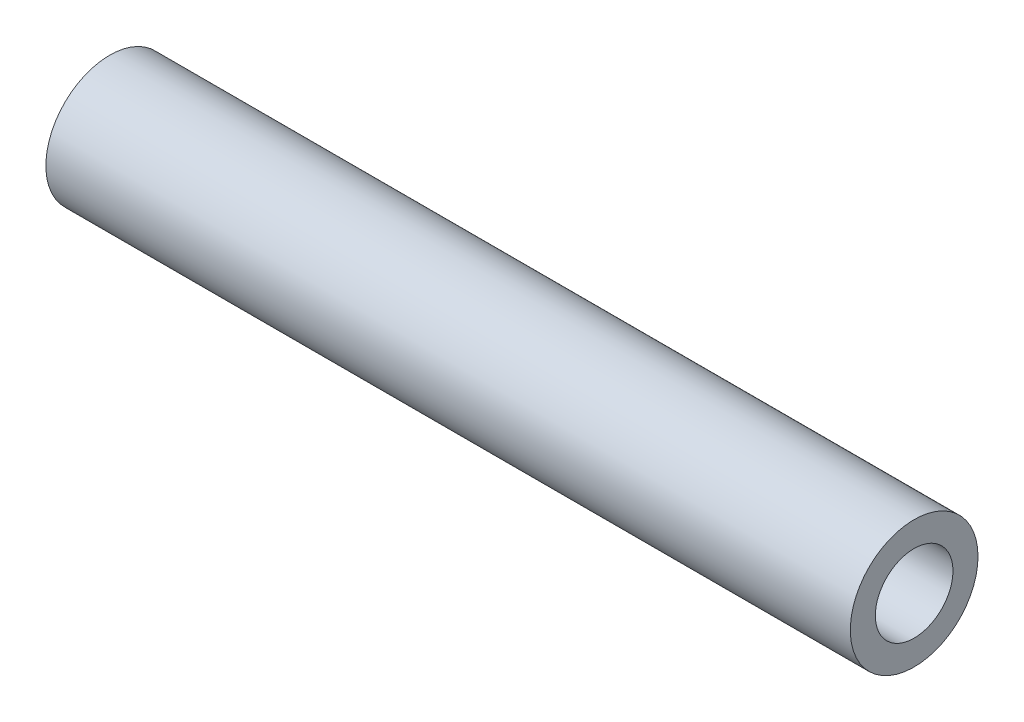
from build123d import *

# Parameters (mm, degrees)
SKETCH1_R           = 3.175
SKETCH1_R_2         = 1.9304
BOSS_EXTRUDE1_DEPTH = 20


with BuildPart() as part:
    # Sketch1 → Boss-Extrude1 (new body, symmetric)
    with BuildSketch(Plane(origin=(0, 0, 0), x_dir=(0, 0, -1), z_dir=(1, 0, 0))):
        Circle(SKETCH1_R)
        Circle(SKETCH1_R_2, mode=Mode.SUBTRACT)
    extrude(amount=BOSS_EXTRUDE1_DEPTH, both=True)


solid = part.part
